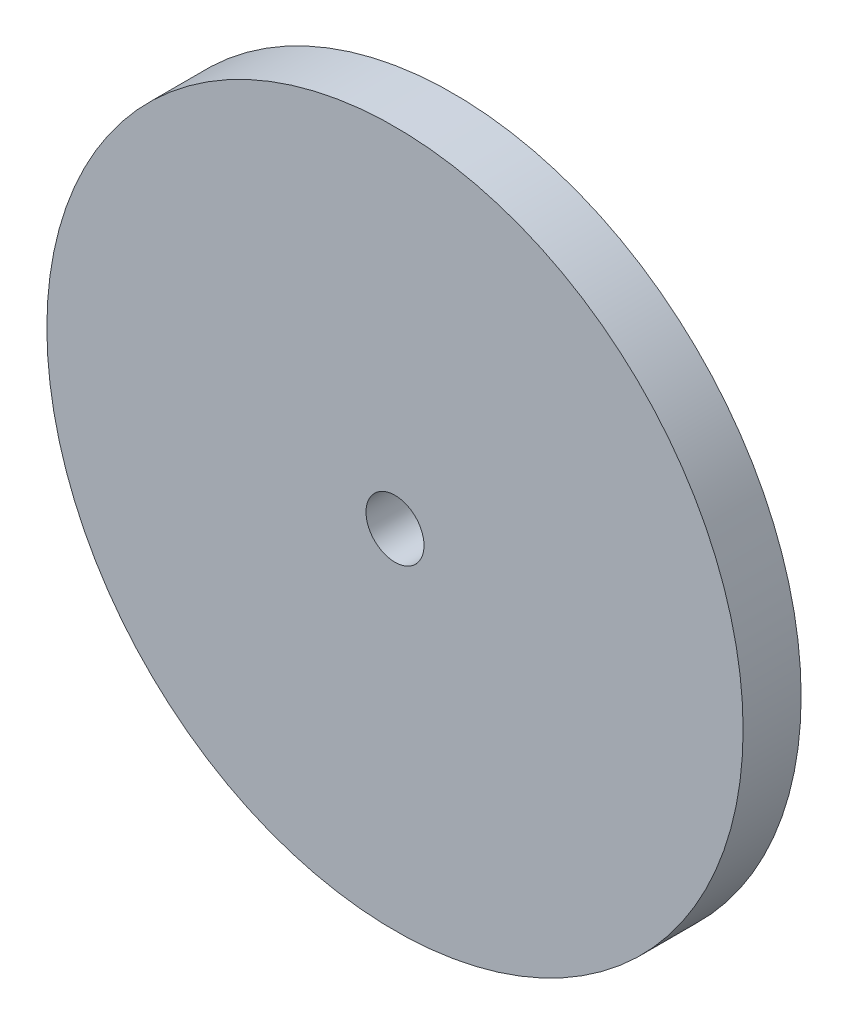
from build123d import *

# Parameters (mm, degrees)
SKETCH1_R           = 38.1
SKETCH1_R_2         = 3.175
BOSS_EXTRUDE1_DEPTH = 6.35


with BuildPart() as part:
    # Sketch1 → Boss-Extrude1 (new body)
    with BuildSketch(Plane.XY):
        Circle(SKETCH1_R)
        Circle(SKETCH1_R_2, mode=Mode.SUBTRACT)
    extrude(amount=BOSS_EXTRUDE1_DEPTH)


solid = part.part
